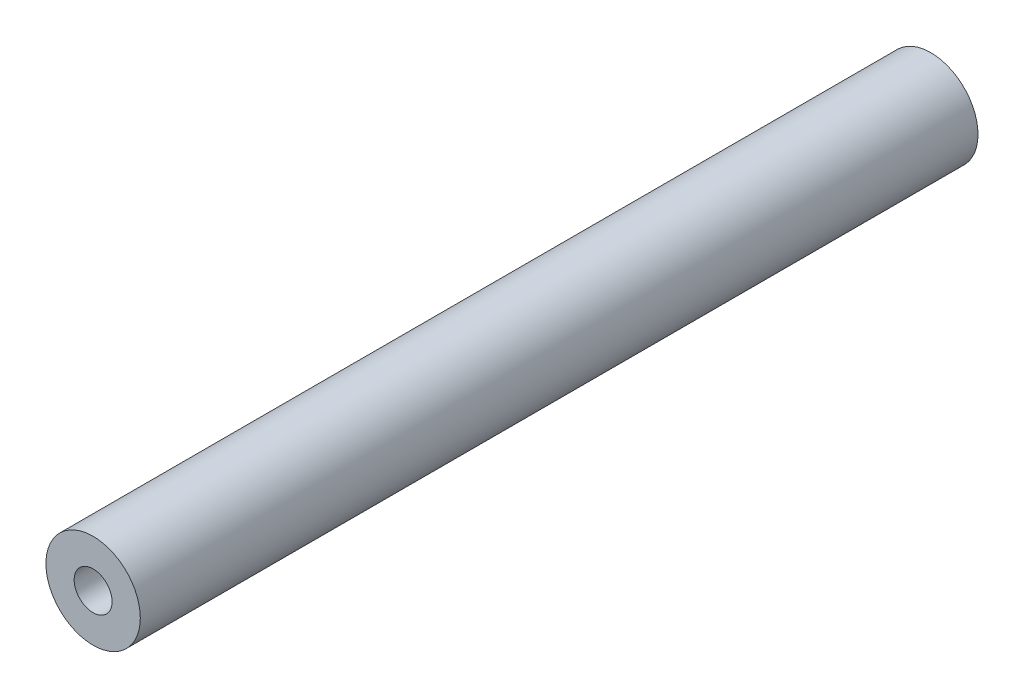
from build123d import *

# Parameters (mm, degrees)
SKETCH1_R                   = 6.35
EXTRUDE1_DEPTH              = 56.35625
F_1_4_20_TAPPED_HOLE1_D     = 5.1054
F_1_4_20_TAPPED_HOLE1_DEPTH = 19.05
F_1_4_20_TAPPED_HOLE1_TIP   = 1.533816902
F_1_4_20_TAPPED_HOLE2_D     = 5.1054
F_1_4_20_TAPPED_HOLE2_DEPTH = 19.05
F_1_4_20_TAPPED_HOLE2_TIP   = 1.533816902


with BuildPart() as part:
    # Sketch1 → Extrude1 (new body, symmetric)
    with BuildSketch(Plane.XY):
        Circle(SKETCH1_R)
    extrude(amount=EXTRUDE1_DEPTH, both=True)

    # 1/4-20 Tapped Hole1
    with Locations(Plane.XY.offset(56.35625)):
        with Locations((0, 0)):
            Hole(F_1_4_20_TAPPED_HOLE1_D / 2, depth=F_1_4_20_TAPPED_HOLE1_DEPTH)
            with Locations((0, 0, -(F_1_4_20_TAPPED_HOLE1_DEPTH + F_1_4_20_TAPPED_HOLE1_TIP / 2))):  # 118° drill point
                Cone(0, F_1_4_20_TAPPED_HOLE1_D / 2, F_1_4_20_TAPPED_HOLE1_TIP, mode=Mode.SUBTRACT)

    # 1/4-20 Tapped Hole2
    with Locations(Plane(origin=(0, 0, -56.35625), x_dir=(-1, 0, 0), z_dir=(0, 0, -1))):
        with Locations((0, 0)):
            Hole(F_1_4_20_TAPPED_HOLE2_D / 2, depth=F_1_4_20_TAPPED_HOLE2_DEPTH)
            with Locations((0, 0, -(F_1_4_20_TAPPED_HOLE2_DEPTH + F_1_4_20_TAPPED_HOLE2_TIP / 2))):  # 118° drill point
                Cone(0, F_1_4_20_TAPPED_HOLE2_D / 2, F_1_4_20_TAPPED_HOLE2_TIP, mode=Mode.SUBTRACT)


solid = part.part
